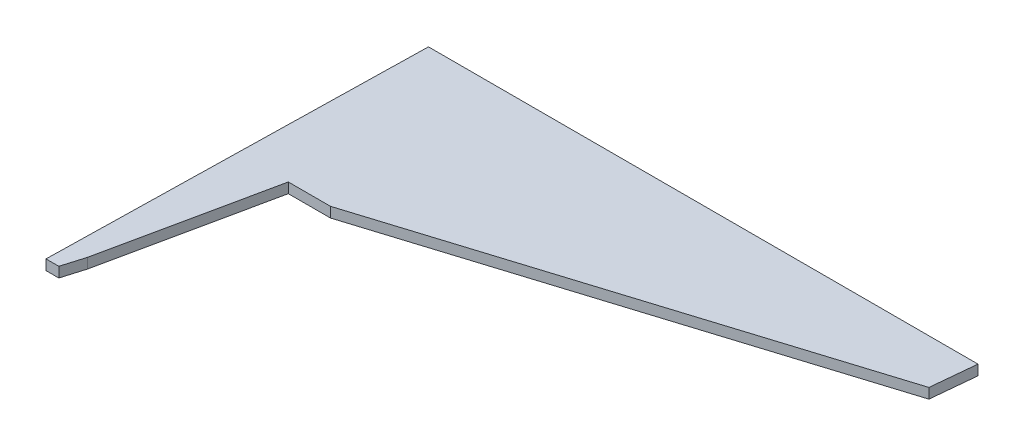
from build123d import *

# Parameters (mm, degrees)
BOSS_EXTRU_1_DEPTH = 2


with BuildPart() as part:
    # Esquisse1 → Boss.-Extru.1 (new body)
    with BuildSketch(Plane(origin=(0, 0, 0), x_dir=(1, 0, 0), z_dir=(0, 1, 0))):
        Polygon((1.494556489, 73.678949979), (0, 0), (2.519477084, 0), (3.808872229, 4.326529616), (10.722218088, 36.905002938), (19.003639691, 36.905002938), (108.645580277, 64.888153315), (109.5030261, 73.678949979), align=None)
    extrude(amount=BOSS_EXTRU_1_DEPTH)


solid = part.part
